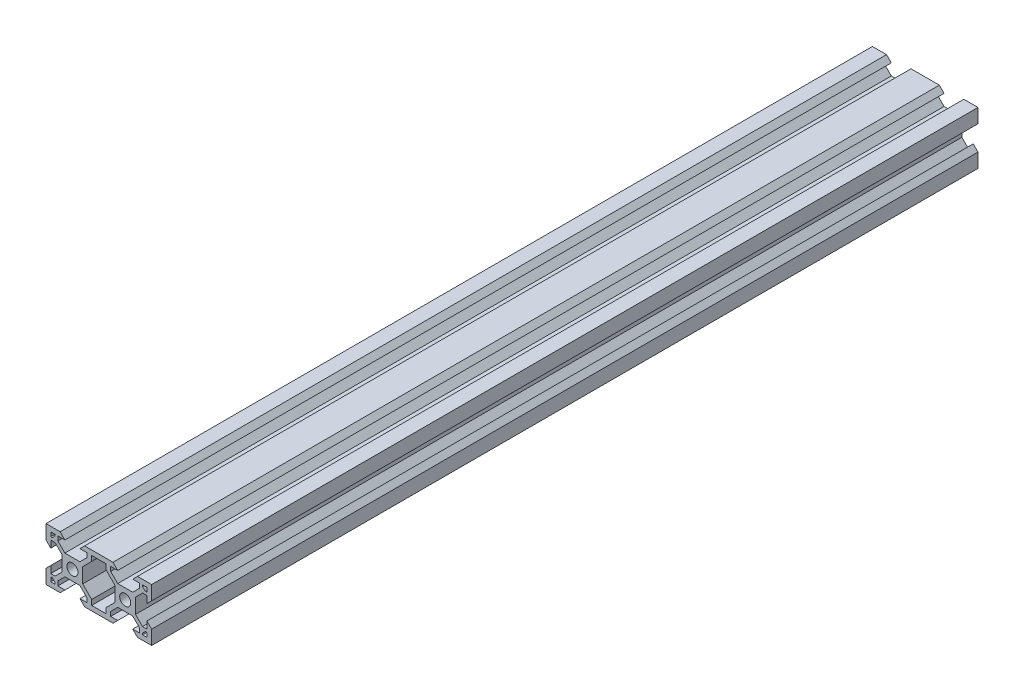
from build123d import *

# Parameters (mm, degrees)
SKETCH1_R           = 2.1
BOSS_EXTRUDE1_DEPTH = 313


with BuildPart() as part:
    # Sketch1 → Boss-Extrude1 (new body)
    with BuildSketch(Plane.XY):
        Polygon((0, 0), (0, 5.36), (1.8, 7.16), (1.8, 4.500660172), (3.44, 4.500660172), (6.099339828, 7.16), (6.099339828, 12.84), (3.44, 15.499339828), (1.8, 15.499339828), (1.8, 12.84), (0, 14.64), (0, 20), (5.36, 20), (7.16, 18.2), (4.500660172, 18.2), (4.500660172, 16.56), (7.16, 13.900660172), (12.84, 13.900660172), (15.499339828, 16.56), (15.499339828, 18.2), (12.84, 18.2), (14.64, 20), (20, 20), (25.36, 20), (27.16, 18.2), (24.500939946, 18.2), (24.50125838, 16.559689577), (27.161114417, 13.900866058), (32.84111431, 13.901968719), (35.499937829, 16.561824756), (35.49961981, 18.2), (32.84, 18.2), (34.64, 20), (39.999930631, 20), (40.000970647, 14.642698508), (38.201320116, 12.842349107), (38.200803857, 15.501688885), (36.560803888, 15.501370511), (33.901980368, 12.841514474), (33.903083029, 7.161514581), (36.562939066, 4.502691062), (38.202939036, 4.503009436), (38.202422777, 7.162349214), (40.002772178, 5.362698683), (40.003813241, 0), (34.64, 0), (32.84, 1.8), (35.502803549, 1.8), (35.502484821, 3.441825004), (32.842628784, 6.100648523), (27.162628891, 6.099545862), (24.503805372, 3.439689825), (24.504123686, 1.8), (27.16, 1.8), (25.36, 0), (20, 0), (14.64, 0), (12.84, 1.8), (15.499339828, 1.8), (15.499339828, 3.44), (12.84, 6.099339828), (7.16, 6.099339828), (4.500660172, 3.44), (4.500660172, 1.8), (7.16, 1.8), (5.36, 0), align=None)
        with Locations((10, 10)):
            Circle(SKETCH1_R, mode=Mode.SUBTRACT)
        with Locations((30, 10)):
            Circle(SKETCH1_R, mode=Mode.SUBTRACT)
        Polygon((17.300660172, 3.76), (17.300660172, 1.8), (22.700660172, 1.8), (22.700660172, 3.76), (26.100660172, 7.16), (26.100660172, 12.84), (22.699339828, 16.24), (22.699339828, 18.2), (17.300660172, 18.2), (17.300660172, 16.24), (13.900660172, 12.84), (13.900660172, 7.16), align=None, mode=Mode.SUBTRACT)
        Polygon((1.8, 18.2), (3.430660172, 18.2), (3.430660172, 17.63), (2.37, 16.569339828), (1.8, 16.569339828), align=None, mode=Mode.SUBTRACT)
        Polygon((1.8, 3.430660172), (1.8, 1.8), (3.430660172, 1.8), (3.430660172, 2.37), (2.37, 3.430660172), align=None, mode=Mode.SUBTRACT)
        Polygon((38.2, 1.8), (36.569339828, 1.8), (36.569339828, 2.37), (37.63, 3.430660172), (38.2, 3.430660172), align=None, mode=Mode.SUBTRACT)
        Polygon((38.2, 16.569339828), (38.2, 18.2), (36.569339828, 18.2), (36.569339828, 17.63), (37.63, 16.569339828), align=None, mode=Mode.SUBTRACT)
    extrude(amount=-BOSS_EXTRUDE1_DEPTH)


solid = part.part
